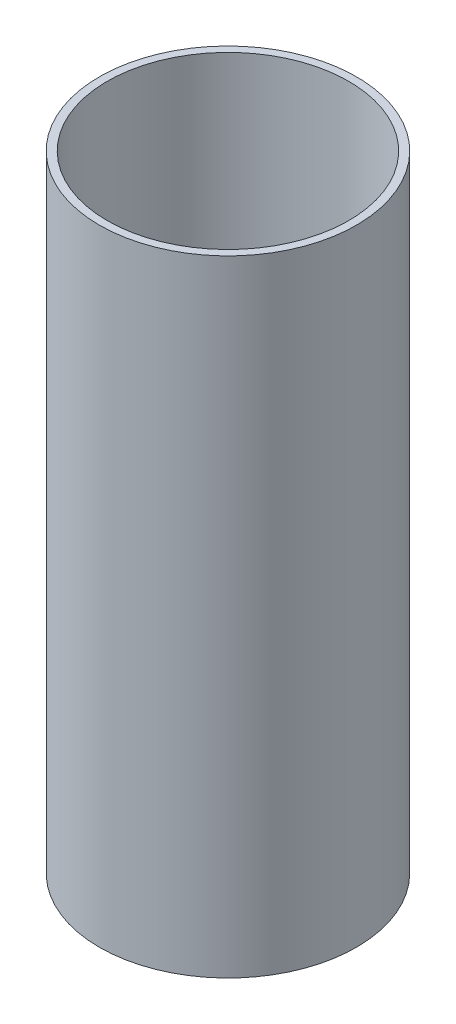
from build123d import *

# Parameters (mm, degrees)
SKETCH1_R           = 20.555
SKETCH1_R_2         = 19.305
BOSS_EXTRUDE1_DEPTH = 100


with BuildPart() as part:
    # Sketch1 → Boss-Extrude1 (new body)
    with BuildSketch(Plane(origin=(0, 0, 0), x_dir=(1, 0, 0), z_dir=(0, 1, 0))):
        Circle(SKETCH1_R)
        Circle(SKETCH1_R_2, mode=Mode.SUBTRACT)
    extrude(amount=BOSS_EXTRUDE1_DEPTH)


solid = part.part
